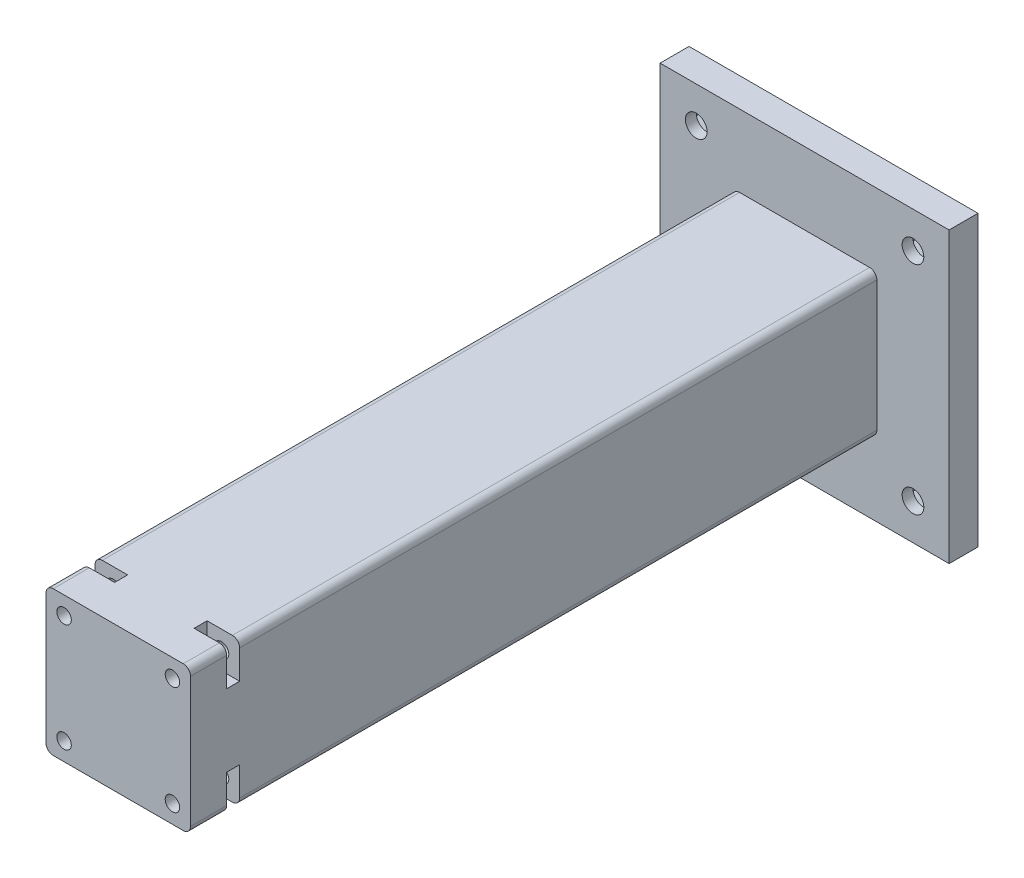
from build123d import *

# Parameters (mm, degrees)
ESQUISSE1_W             = 40
ESQUISSE1_H             = 40
BOSS_EXTRU_1_DEPTH      = 4
ESQUISSE4_W             = 20
ESQUISSE4_H             = 20
BOSS_EXTRU_4_DEPTH      = 95
CONG_3_R                = 1
ESQUISSE5_R             = 1
ENL_V_MAT_EXTRU_1_DEPTH = 20
ESQUISSE6_W             = 4.5
ESQUISSE6_H             = 1.8
ENL_V_MAT_EXTRU_2_DEPTH = 5
ESQUISSE7_R             = 1.5
ENL_V_MAT_EXTRU_3_DEPTH = 4
ENL_V_MAT_EXTRU_4_DEPTH = 2.5


with BuildPart() as part:
    # Esquisse1 → Boss.-Extru.1 (new body)
    with BuildSketch(Plane.XY):
        Rectangle(ESQUISSE1_W, ESQUISSE1_H)
    extrude(amount=BOSS_EXTRU_1_DEPTH)

    # Esquisse4 → Boss.-Extru.4 (add)
    with BuildSketch(Plane.XY.offset(4)):
        Rectangle(ESQUISSE4_W, ESQUISSE4_H)
    extrude(amount=BOSS_EXTRU_4_DEPTH)

    # Congé3
    cong_3_edges = [part.edges().sort_by_distance(p)[0] for p in [
        (-10, 10, 51.5),
        (-10, -10, 51.5),
        (10, -10, 51.5),
        (10, 10, 51.5),
    ]]
    fillet(cong_3_edges, radius=CONG_3_R)

    # Esquisse5 → Enlèv. mat.-Extru.1 (cut)
    with BuildSketch(Plane.XY.offset(99)):
        with Locations((7.5, 7.5)):
            Circle(ESQUISSE5_R)
        with Locations((-7.5, 7.5)):
            Circle(ESQUISSE5_R)
        with Locations((-7.5, -7.5)):
            Circle(ESQUISSE5_R)
        with Locations((7.5, -7.5)):
            Circle(ESQUISSE5_R)
    extrude(amount=-ENL_V_MAT_EXTRU_1_DEPTH, mode=Mode.SUBTRACT)

    # Esquisse6 → Enlèv. mat.-Extru.2 (cut)
    with BuildSketch(Plane.XZ.offset(10)):
        with Locations((-7.75, 93.1)):
            Rectangle(ESQUISSE6_W, ESQUISSE6_H)
        with Locations((7.75, 93.1)):
            Rectangle(ESQUISSE6_W, ESQUISSE6_H)
    enl_v_mat_extru_2 = extrude(amount=-ENL_V_MAT_EXTRU_2_DEPTH, mode=Mode.SUBTRACT)

    # Symétrie1: Enlèv. mat.-Extru.2 across plane
    add(enl_v_mat_extru_2.mirror(Plane.ZX), mode=Mode.SUBTRACT)

    # Esquisse7 → Enlèv. mat.-Extru.3 (cut)
    with BuildSketch(Plane(origin=(0, 0, 0), x_dir=(-1, 0, 0), z_dir=(0, 0, -1))):
        with Locations((15, 15)):
            Circle(ESQUISSE7_R)
        with Locations((15, -15)):
            Circle(ESQUISSE7_R)
        with Locations((-15, -15)):
            Circle(ESQUISSE7_R)
        with Locations((-15, 15)):
            Circle(ESQUISSE7_R)
    extrude(amount=-ENL_V_MAT_EXTRU_3_DEPTH, mode=Mode.SUBTRACT)

    # Esquisse8 → Enlèv. mat.-Extru.4 (cut)
    with BuildSketch(Plane(origin=(0, 0, 0), x_dir=(-1, 0, 0), z_dir=(0, 0, -1))):
        Polygon((-12.228718708, 13.4), (-12.228718708, 16.6), (-15, 18.2), (-17.771281292, 16.6), (-17.771281292, 13.4), (-15, 11.8), align=None)
        Polygon((15, 11.8), (17.771281292, 13.4), (17.771281292, 16.6), (15, 18.2), (12.228718708, 16.6), (12.228718708, 13.4), align=None)
        Polygon((15, -18.2), (17.771281292, -16.6), (17.771281292, -13.4), (15, -11.8), (12.228718708, -13.4), (12.228718708, -16.6), align=None)
        Polygon((-12.228718708, -16.6), (-12.228718708, -13.4), (-15, -11.8), (-17.771281292, -13.4), (-17.771281292, -16.6), (-15, -18.2), align=None)
    extrude(amount=-ENL_V_MAT_EXTRU_4_DEPTH, mode=Mode.SUBTRACT)


solid = part.part
